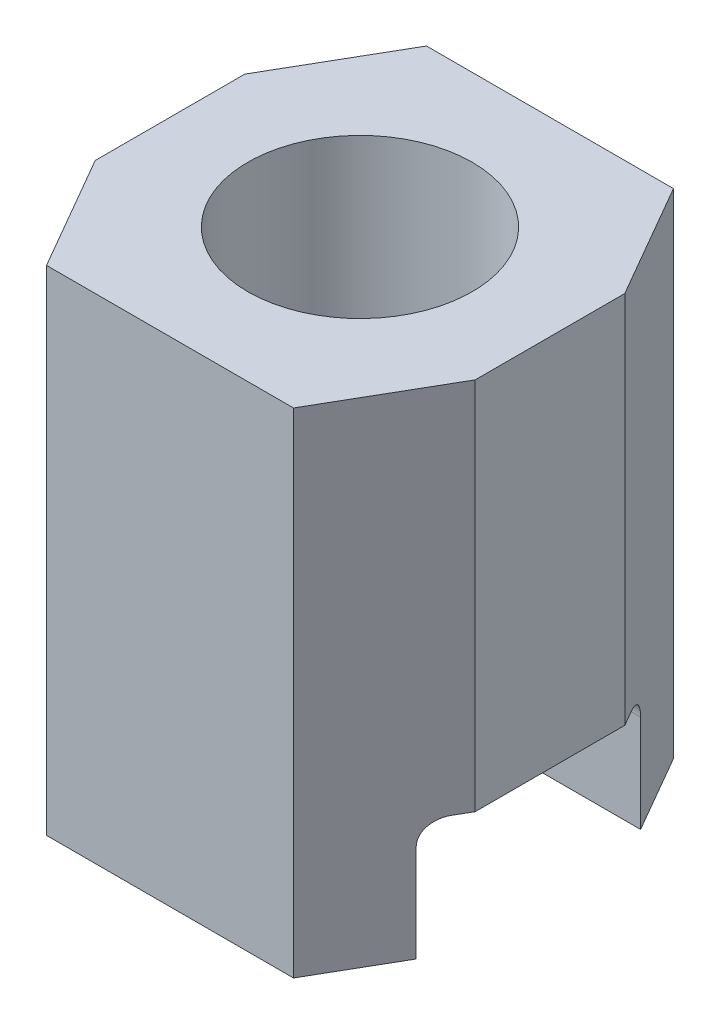
from build123d import *

# Parameters (mm, degrees)
SKETCH1_R           = 0.675
BOSS_EXTRUDE1_DEPTH = 3.3
CUT_EXTRUDE1_REACH  = 4.54
SKETCH3_R           = 0.75
CUT_EXTRUDE2_DEPTH  = 2


with BuildPart() as part:
    # Sketch1 → Boss-Extrude1 (new body)
    with BuildSketch(Plane(origin=(0, 0, 0), x_dir=(1, 0, 0), z_dir=(0, 1, 0))):
        Polygon((-0.825440293, 1.27), (0.825440293, 1.27), (1.27, 0.5), (1.27, -0.5), (0.825440293, -1.27), (-0.825440293, -1.27), (-1.27, -0.5), (-1.27, 0.5), align=None)
        Circle(SKETCH1_R, mode=Mode.SUBTRACT)
    extrude(amount=BOSS_EXTRUDE1_DEPTH)

    # Sketch2 → Cut-Extrude1 (cut, up to next)
    with BuildSketch(Plane.ZY.offset(1.27), mode=Mode.PRIVATE) as cut_extrude1_sk1:
        with BuildLine():
            Line((-0.75, 0), (0.75, 0))
            Line((0.75, 0), (0.75, 0.65))
            ThreePointArc((0.75, 0.65), (0.706066017, 0.756066017), (0.6, 0.8))
            Line((0.6, 0.8), (-0.6, 0.8))
            ThreePointArc((-0.6, 0.8), (-0.706066017, 0.756066017), (-0.75, 0.65))
            Line((-0.75, 0.65), (-0.75, 0))
        make_face()
    cut_extrude1_tool1 = extrude(cut_extrude1_sk1.sketch, amount=-CUT_EXTRUDE1_REACH, mode=Mode.PRIVATE) & part.part
    add(cut_extrude1_tool1.solids().sort_by_distance((-1.27, 0.397027, 0))[0], mode=Mode.SUBTRACT)

    # Sketch3 → Cut-Extrude2 (cut)
    with BuildSketch(Plane(origin=(0, 3.3, 0), x_dir=(1, 0, 0), z_dir=(0, 1, 0))):
        Circle(SKETCH3_R)
    extrude(amount=-CUT_EXTRUDE2_DEPTH, mode=Mode.SUBTRACT)


solid = part.part
